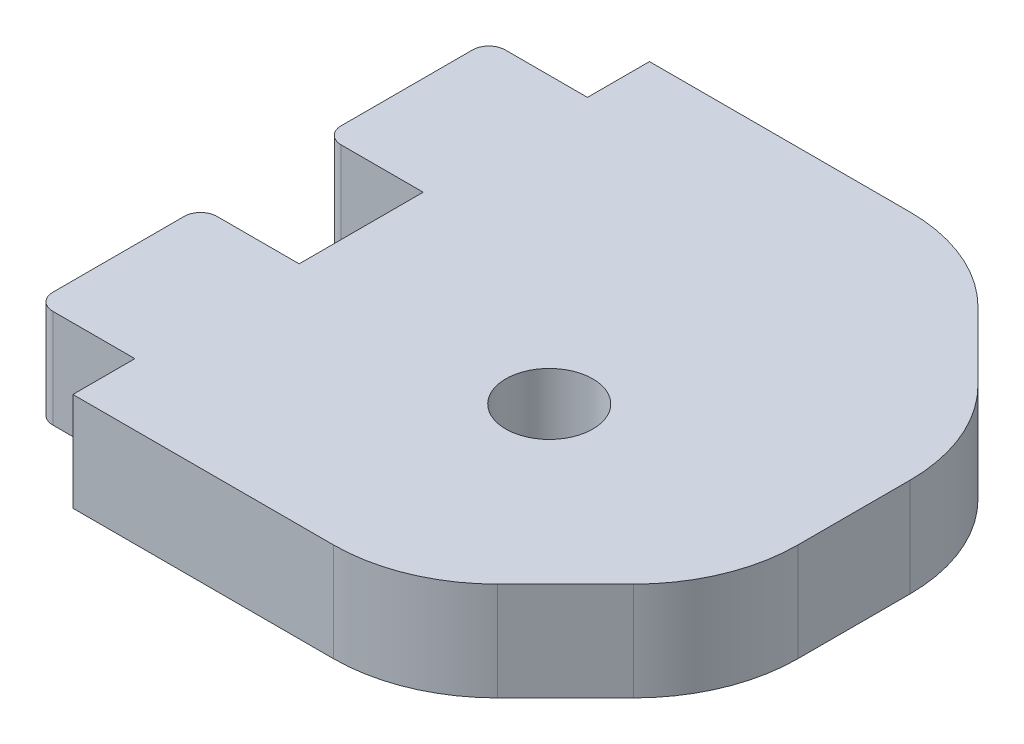
from build123d import *

# Parameters (mm, degrees)
SKETCH1_W              = 30
SKETCH1_H              = 35.1
BOSS_EXTRUDE1_DEPTH    = 6
CHAMFER1_SIZE          = 10
M5_CLEARANCE_HOLE1_D   = 5.3
SKETCH234_W            = 10
SKETCH234_H            = 6
BOSS_EXTRUDE234_DEPTH  = 6
FILLET134_R            = 1
SKETCH2341_W           = 10
SKETCH2341_H           = 6
BOSS_EXTRUDE2341_DEPTH = 6
FILLET1341_R           = 1
FILLET1342_R           = 10


with BuildPart() as part:
    # Sketch1 → Boss-Extrude1 (new body)
    with BuildSketch(Plane(origin=(0, 0, 0), x_dir=(1, 0, 0), z_dir=(0, 1, 0))):
        with Locations((15, 17.55)):
            Rectangle(SKETCH1_W, SKETCH1_H)
    extrude(amount=BOSS_EXTRUDE1_DEPTH)

    # Chamfer1
    chamfer1_edges = [part.edges().sort_by_distance(p)[0] for p in [
        (30, 3, -35.1),
        (30, 3, 0),
    ]]
    chamfer(chamfer1_edges, length=CHAMFER1_SIZE)

    # M5 Clearance Hole1 (through all)
    with Locations(Plane(origin=(0, 0, 0), x_dir=(-1, 0, 0), z_dir=(0, -1, 0))):
        with Locations((-15, 14)):
            Hole(M5_CLEARANCE_HOLE1_D / 2)

    # Sketch234 → Boss-Extrude234 (add)
    with BuildSketch(Plane(origin=(0, 6, -8.007221392), x_dir=(0, 0, -1), z_dir=(-1, 0, 0))):
        with Locations((0.767778608, 3)):
            Rectangle(SKETCH234_W, SKETCH234_H)
    extrude(amount=BOSS_EXTRUDE234_DEPTH)

    # Fillet134
    fillet134_edges = [part.edges().sort_by_distance(p)[0] for p in [
        (-6, 3, -3.775),
        (-6, 3, -13.775),
    ]]
    fillet(fillet134_edges, radius=FILLET134_R)

    # Sketch2341 → Boss-Extrude2341 (add)
    with BuildSketch(Plane(origin=(0, 0, -27.092778608), x_dir=(0, 0, 1), z_dir=(-1, 0, 0))):
        with Locations((0.767778608, 3)):
            Rectangle(SKETCH2341_W, SKETCH2341_H)
    extrude(amount=BOSS_EXTRUDE2341_DEPTH)

    # Fillet1341
    fillet1341_edges = [part.edges().sort_by_distance(p)[0] for p in [
        (-6, 3, -21.325),
        (-6, 3, -31.325),
    ]]
    fillet(fillet1341_edges, radius=FILLET1341_R)

    # Fillet1342
    fillet1342_edges = [part.edges().sort_by_distance(p)[0] for p in [
        (20, 3, -35.1),
        (30, 3, -10),
        (30, 3, -25.1),
        (20, 3, 0),
    ]]
    fillet(fillet1342_edges, radius=FILLET1342_R)


solid = part.part
